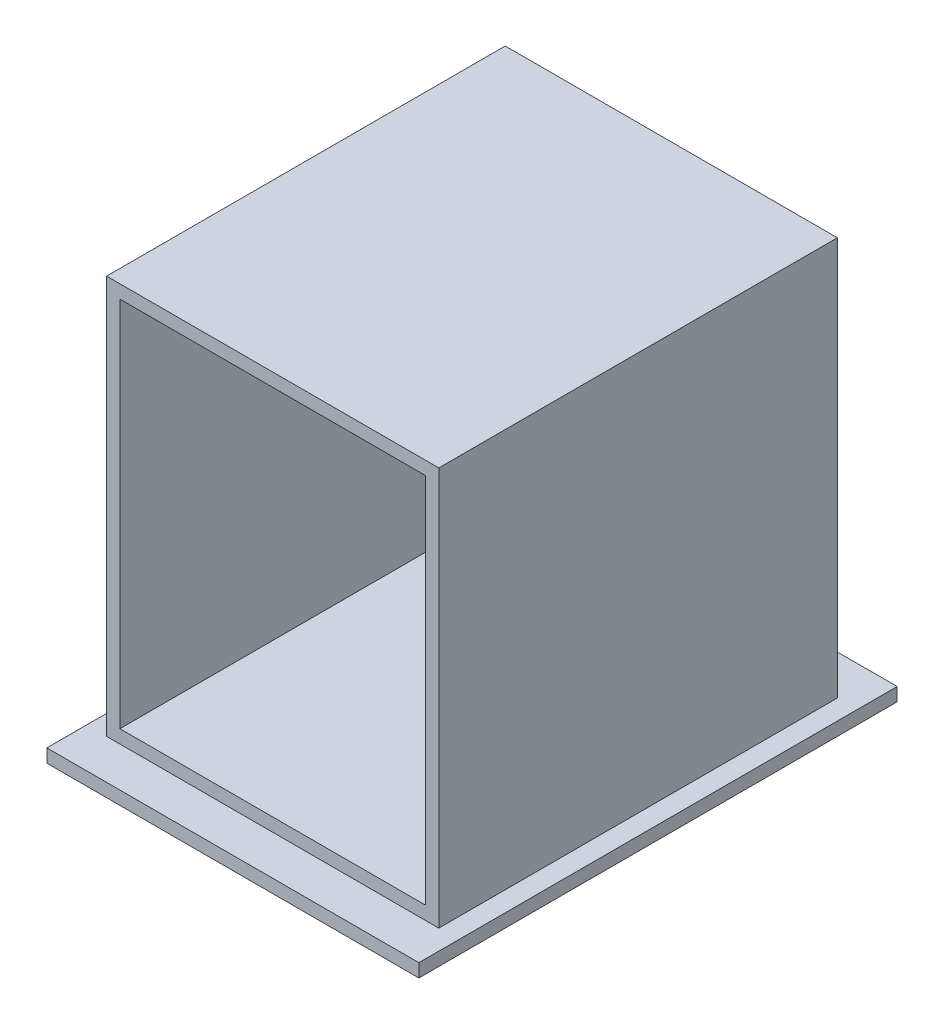
from build123d import *

# Parameters (mm, degrees)
SKETCH_1_W          = 250
SKETCH_1_H          = 300
EXTRUDE_1_DEPTH     = 300
SKETCH_2_W          = 230
SKETCH_2_H          = 280
CUT_EXTRUDE_1_DEPTH = 290
SKETCH_3_W          = 280
SKETCH_3_H          = 360
EXTRUDE_2_DEPTH     = 10
CUT_EXTRUDE_2_DEPTH = 10


with BuildPart() as part:
    # 草图1 → 凸台-拉伸1 (new body)
    with BuildSketch(Plane.XY):
        with Locations((125, 150)):
            Rectangle(SKETCH_1_W, SKETCH_1_H)
    extrude(amount=EXTRUDE_1_DEPTH)

    # 草图2 → 切除-拉伸1 (cut)
    with BuildSketch(Plane.XY.offset(300)):
        with Locations((125, 150)):
            Rectangle(SKETCH_2_W, SKETCH_2_H)
    extrude(amount=-CUT_EXTRUDE_1_DEPTH, mode=Mode.SUBTRACT)

    # 草图3 → 凸台-拉伸2 (add)
    with BuildSketch(Plane.XZ):
        with Locations((125, 150)):
            Rectangle(SKETCH_3_W, SKETCH_3_H)
    extrude(amount=EXTRUDE_2_DEPTH)

    # 草图4 → 切除-拉伸2 (cut)
    with BuildSketch(Plane.XZ.offset(10)):
        with BuildLine():
            Line((92.011234141, 284.219295629), (173.345605139, 284.219295629))
            ThreePointArc((173.345605139, 284.219295629), (187.564900768, 270), (173.345605139, 255.780704371))
            Line((173.345605139, 255.780704371), (92.011234141, 255.780704371))
            ThreePointArc((92.011234141, 255.780704371), (77.791938512, 270), (92.011234141, 284.219295629))
        make_face()
    extrude(amount=-CUT_EXTRUDE_2_DEPTH, mode=Mode.SUBTRACT)


solid = part.part
